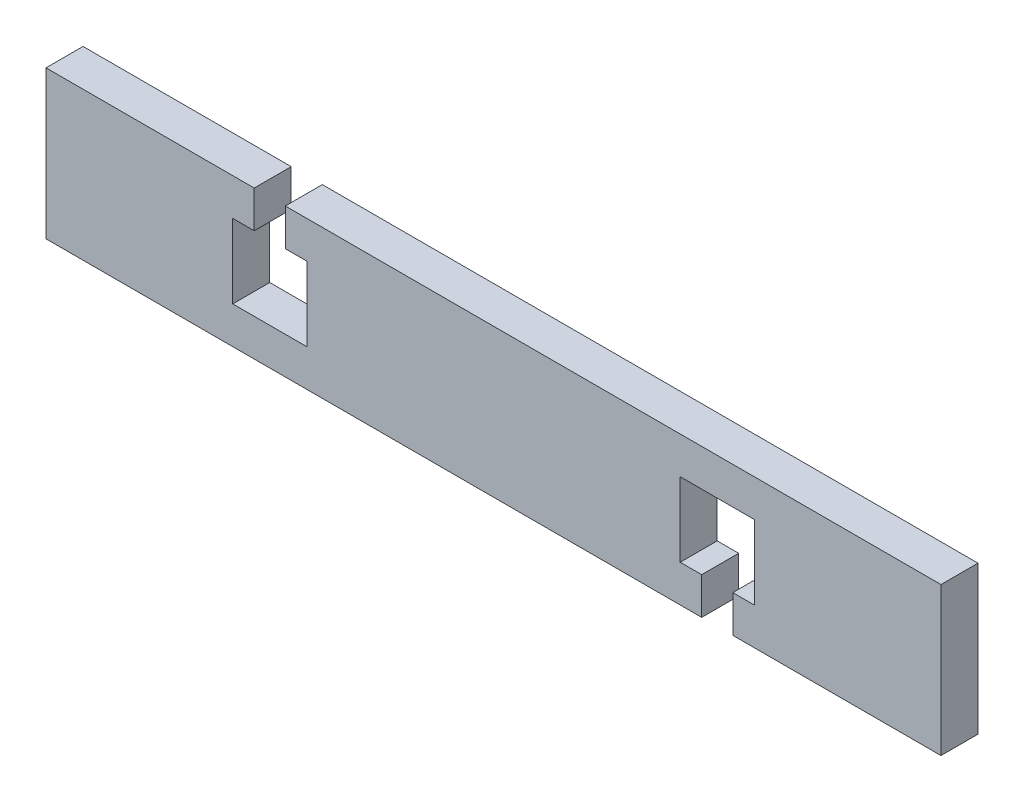
from build123d import *

# Parameters (mm, degrees)
BOSS_EXTRUDE1_DEPTH = 5


with BuildPart() as part:
    # Sketch1 → Boss-Extrude1 (new body)
    with BuildSketch(Plane.XY):
        Polygon((60.425, -10), (32.3125, -10), (32.3125, -5), (35.2125, -5), (35.2125, 5), (25.2125, 5), (25.2125, -5), (28.1125, -5), (28.1125, -10), (-60.425, -10), (-60.425, 10), (-32.3125, 10), (-32.3125, 5), (-35.2125, 5), (-35.2125, -5), (-30.2125, -5), (-25.2125, -5), (-25.2125, 5), (-28.1125, 5), (-28.1125, 10), (60.425, 10), align=None)
    extrude(amount=BOSS_EXTRUDE1_DEPTH)


solid = part.part
